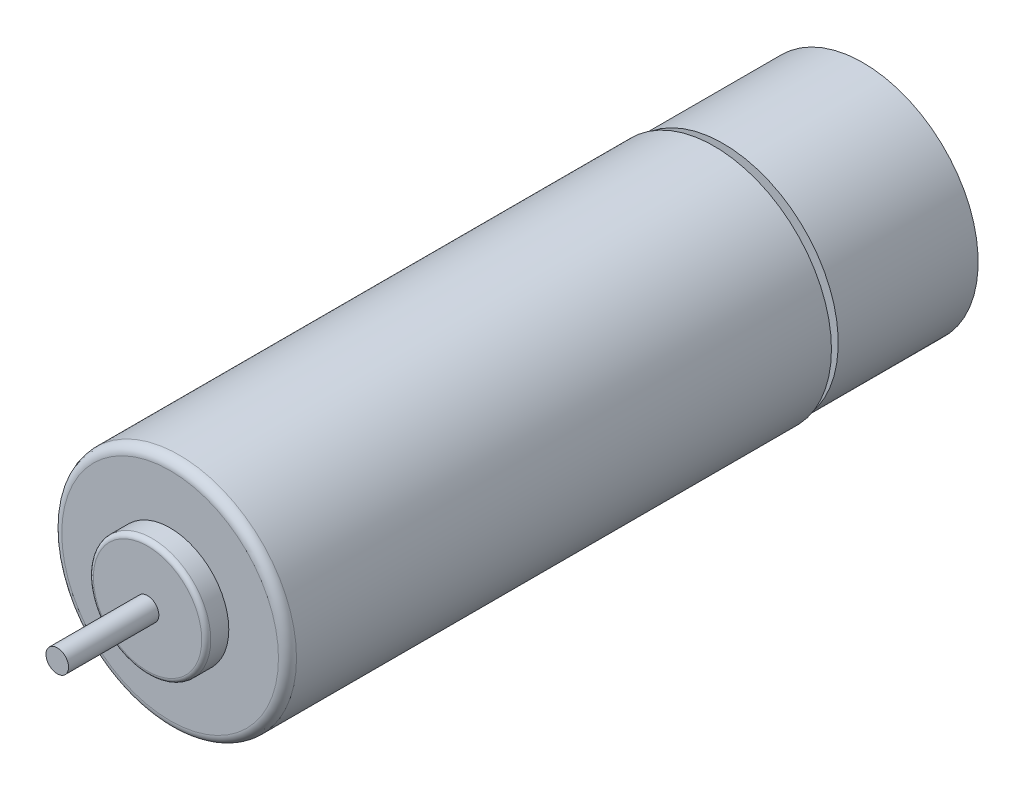
from build123d import *

# Parameters (mm, degrees)
SKETCH_1_R               = 26
EXTRUDE_1_DEPTH          = 120.5
SKETCH_2_R               = 13
EXTRUDE_2_DEPTH          = 5
SKETCH_3_R               = 2.5
EXTRUDE_3_DEPTH          = 20
SKETCH_7_R               = 2.5
EXTRUDE_7_DEPTH          = 25
FILLET_2_R               = 2
FILLET_3_R               = 1
SKETCH_4_R               = 25.5
SKETCH_4_R_2             = 22.5
EXTRUDE_4_DEPTH          = 28
SKETCH_5_R               = 25.5
SKETCH_5_R_2             = 17.5
EXTRUDE_5_DEPTH          = 3
SKETCH_6_R               = 2.5
EXTRUDE_6_DEPTH          = 31
PATTERN_CIRCULAR_1_COUNT = 6


with BuildPart() as part:
    # 草图1 → 凸台-拉伸1 (new body)
    with BuildSketch(Plane.XY):
        Circle(SKETCH_1_R)
    extrude(amount=EXTRUDE_1_DEPTH)

    # 草图2 → 凸台-拉伸2 (add)
    with BuildSketch(Plane.XY.offset(120.5)):
        Circle(SKETCH_2_R)
    extrude(amount=EXTRUDE_2_DEPTH)

    # 草图3 → 凸台-拉伸3 (add)
    with BuildSketch(Plane.XY.offset(125.5)):
        Circle(SKETCH_3_R)
    extrude(amount=EXTRUDE_3_DEPTH)

    # 草图7 → 凸台-拉伸7 (add)
    with BuildSketch(Plane(origin=(0, 0, 0), x_dir=(-1, 0, 0), z_dir=(0, 0, -1))):
        Circle(SKETCH_7_R)
    extrude(amount=EXTRUDE_7_DEPTH)

    # 圆角2
    fillet_2_edges = [part.edges().sort_by_distance(p)[0] for p in [
        (-26, 0, 120.5),
    ]]
    fillet(fillet_2_edges, radius=FILLET_2_R)

    # 圆角3
    fillet_3_edges = [part.edges().sort_by_distance(p)[0] for p in [
        (-13, 0, 125.5),
    ]]
    fillet(fillet_3_edges, radius=FILLET_3_R)


with BuildPart() as body_2:
    # 草图4 → 凸台-拉伸4 (new body)
    with BuildSketch(Plane(origin=(0, 0, -2), x_dir=(-1, 0, 0), z_dir=(0, 0, -1))):
        Circle(SKETCH_4_R)
        Circle(SKETCH_4_R_2, mode=Mode.SUBTRACT)
    extrude(amount=EXTRUDE_4_DEPTH)

    # 草图5 → 凸台-拉伸5 (add)
    with BuildSketch(Plane(origin=(0, 0, -30), x_dir=(-1, 0, 0), z_dir=(0, 0, -1))):
        Circle(SKETCH_5_R)
        Circle(SKETCH_5_R_2, mode=Mode.SUBTRACT)
    extrude(amount=EXTRUDE_5_DEPTH)

    # 草图6 → 凸台-拉伸6 (add)
    with BuildSketch(Plane(origin=(0, 0, -33), x_dir=(-1, 0, 0), z_dir=(0, 0, -1))):
        with BuildLine():
            Line((-1, 3.877336352), (-2, 25.421447638))
            ThreePointArc((-2, 25.421447638), (0, 25.5), (2, 25.421447638))
            Line((2, 25.421447638), (1, 3.877336352))
            ThreePointArc((1, 3.877336352), (0, -4.004214927), (-1, 3.877336352))
        make_face()
        Circle(SKETCH_6_R, mode=Mode.SUBTRACT)
    extrude_6 = extrude(amount=-EXTRUDE_6_DEPTH)

    # 阵列(圆周)1: 凸台-拉伸6 ×6 about axis
    pattern_circular_1_axis = Axis((0, 0, 0), (0, 0, 1))
    for i in range(1, PATTERN_CIRCULAR_1_COUNT):
        add(extrude_6.rotate(pattern_circular_1_axis, i * 360 / PATTERN_CIRCULAR_1_COUNT))


solid = Compound([part.part, body_2.part])
